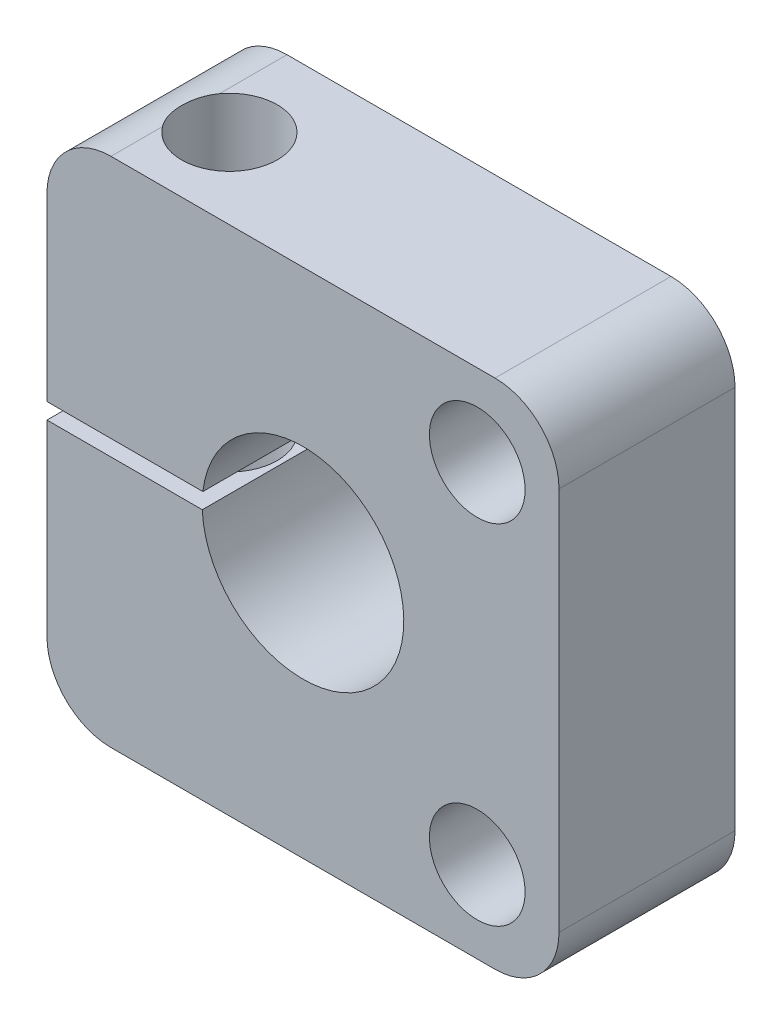
from build123d import *

# Parameters (mm, degrees)
SKETCH1_W                 = 20.32
SKETCH1_H                 = 20.32
BOSS_EXTRUDE1_DEPTH       = 6.985
SKETCH5_W                 = 22.86
SKETCH5_H                 = 0.635
CUT_EXTRUDE3_DEPTH        = 1
CUT_EXTRUDE3_DEPTH_BACK   = 7.985
F_6_CLEARANCE_HOLE1_D     = 3.7973
F_6_CLEARANCE_HOLE1_DEPTH = 6.985
FILLET1_R                 = 2.54
F_8_0MM_DOWEL_HOLE1_D     = 8
F_8_0MM_DOWEL_HOLE1_DEPTH = 6.985
F_6_CLEARANCE_HOLE2_D     = 3.7973


with BuildPart() as part:
    # Sketch1 → Boss-Extrude1 (new body)
    with BuildSketch(Plane.XY):
        Rectangle(SKETCH1_W, SKETCH1_H)
    extrude(amount=BOSS_EXTRUDE1_DEPTH)

    # Sketch5 → Cut-Extrude3 (cut, two sides)
    with BuildSketch(Plane.XY.offset(6.985)) as cut_extrude3_sk:
        with Locations((-15.137429848, 0.144302155)):
            Rectangle(SKETCH5_W, SKETCH5_H)
    extrude(amount=CUT_EXTRUDE3_DEPTH, mode=Mode.SUBTRACT)
    extrude(cut_extrude3_sk.sketch, amount=-CUT_EXTRUDE3_DEPTH_BACK, mode=Mode.SUBTRACT)

    # #6 Clearance Hole1
    with Locations(Plane.XY.offset(6.985)):
        with Locations((6.914797213, 6.914797213), (6.914797213, -6.914797213)):
            Hole(F_6_CLEARANCE_HOLE1_D / 2, depth=F_6_CLEARANCE_HOLE1_DEPTH)

    # Fillet1
    fillet1_edges = [part.edges().sort_by_distance(p)[0] for p in [
        (10.16, -10.16, 3.4925),
        (-10.16, -10.16, 3.4925),
        (-10.16, 10.16, 3.4925),
        (10.16, 10.16, 3.4925),
    ]]
    fillet(fillet1_edges, radius=FILLET1_R)

    # Ø8.0mm Dowel Hole1
    with Locations(Plane.XY.offset(6.985)):
        with Locations((0, 0)):
            Hole(F_8_0MM_DOWEL_HOLE1_D / 2, depth=F_8_0MM_DOWEL_HOLE1_DEPTH)

    # #6 Clearance Hole2 (through all)
    with Locations(Plane(origin=(0, 10.16, 0), x_dir=(1, 0, 0), z_dir=(0, 1, 0))):
        with Locations((-6.096, -3.81)):
            Hole(F_6_CLEARANCE_HOLE2_D / 2)


solid = part.part
